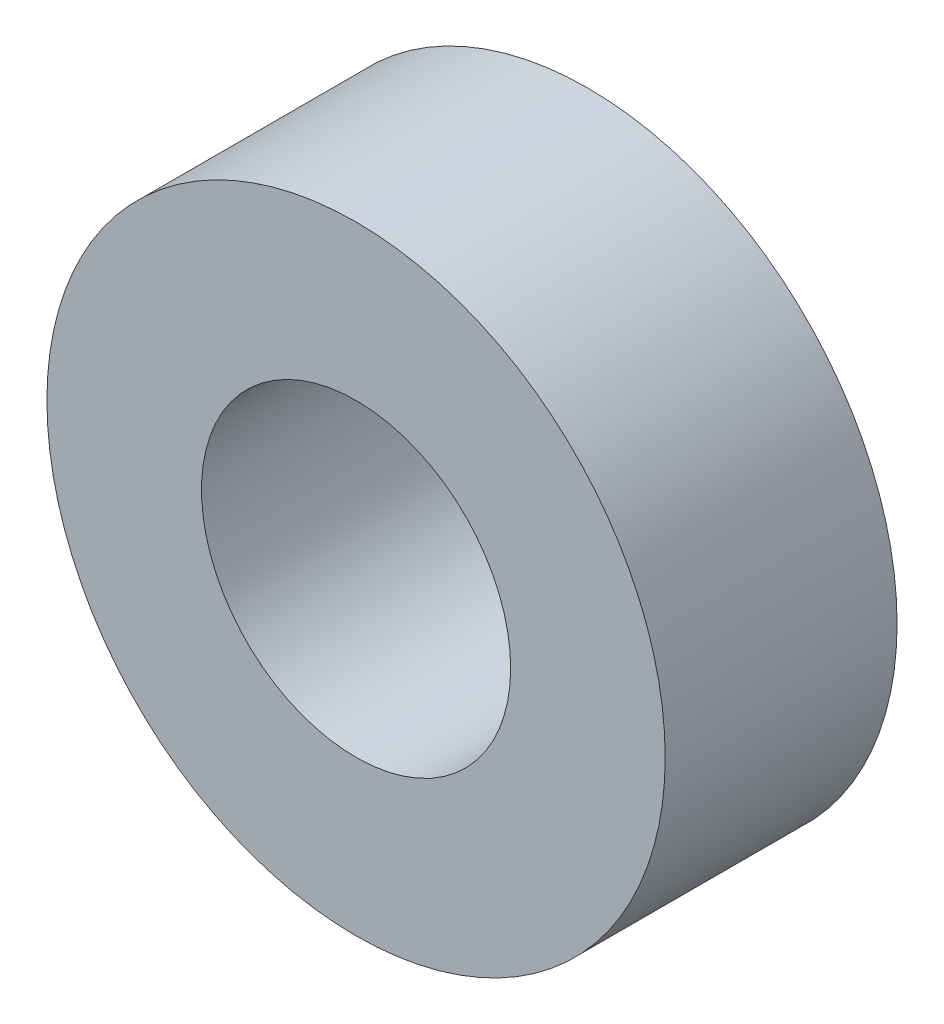
from build123d import *

# Parameters (mm, degrees)
SKETCH1_R           = 25.4
SKETCH1_R_2         = 12.7
BOSS_EXTRUDE1_DEPTH = 9.525


with BuildPart() as part:
    # Sketch1 → Boss-Extrude1 (new body, symmetric)
    with BuildSketch(Plane.XY):
        Circle(SKETCH1_R)
        Circle(SKETCH1_R_2, mode=Mode.SUBTRACT)
    extrude(amount=BOSS_EXTRUDE1_DEPTH, both=True)


solid = part.part
